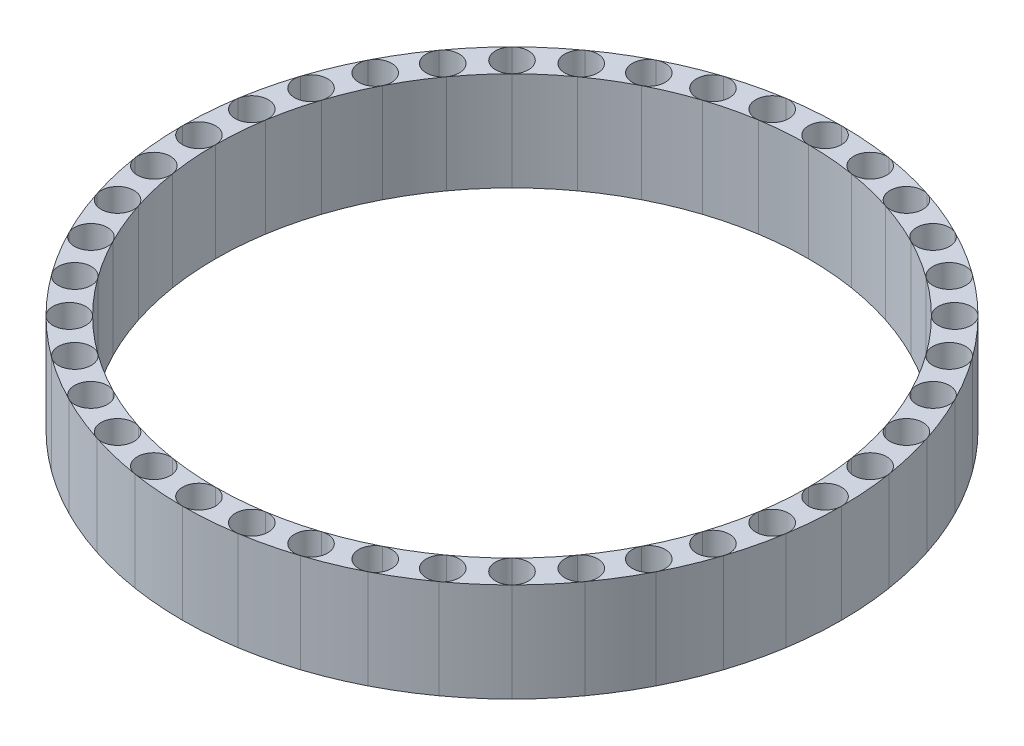
from build123d import *

# Parameters (mm, degrees)
SKETCH1_R           = 127
BOSS_EXTRUDE2_DEPTH = 38.1
SKETCH5_R           = 114.3
CUT_EXTRUDE1_DEPTH  = 39.1
SKETCH6_R           = 6.35
CUT_EXTRUDE2_DEPTH  = 39.1


with BuildPart() as part:
    # Sketch1 → Boss-Extrude2 (new body)
    with BuildSketch(Plane(origin=(0, 0, 0), x_dir=(1, 0, 0), z_dir=(0, 1, 0))):
        Circle(SKETCH1_R)
    extrude(amount=BOSS_EXTRUDE2_DEPTH)

    # Sketch5 → Cut-Extrude1 (cut, through all)
    with BuildSketch(Plane(origin=(0, 38.1, 0), x_dir=(1, 0, 0), z_dir=(0, 1, 0))):
        Circle(SKETCH5_R)
    extrude(amount=-CUT_EXTRUDE1_DEPTH, mode=Mode.SUBTRACT)

    # Sketch6 → Cut-Extrude2 (cut, through all)
    with BuildSketch(Plane(origin=(0, 0, 0), x_dir=(-1, 0, 0), z_dir=(0, -1, 0))):
        with Locations((0, 120.65)):
            Circle(SKETCH6_R)
        with Locations((18.873818207, 119.164598293)):
            Circle(SKETCH6_R)
        with Locations((37.282900371, 114.744968691)):
            Circle(SKETCH6_R)
        with Locations((54.773953794, 107.499937143)):
            Circle(SKETCH6_R)
        with Locations((70.916290689, 97.607900371)):
            Circle(SKETCH6_R)
        with Locations((85.31243315, 85.31243315)):
            Circle(SKETCH6_R)
        with Locations((97.607900371, 70.916290689)):
            Circle(SKETCH6_R)
        with Locations((107.499937143, 54.773953794)):
            Circle(SKETCH6_R)
        with Locations((114.744968691, 37.282900371)):
            Circle(SKETCH6_R)
        with Locations((119.164598293, 18.873818207)):
            Circle(SKETCH6_R)
        with Locations((120.65, 0)):
            Circle(SKETCH6_R)
        with Locations((119.164598293, -18.873818207)):
            Circle(SKETCH6_R)
        with Locations((114.744968691, -37.282900371)):
            Circle(SKETCH6_R)
        with Locations((107.499937143, -54.773953794)):
            Circle(SKETCH6_R)
        with Locations((97.607900371, -70.916290689)):
            Circle(SKETCH6_R)
        with Locations((85.31243315, -85.31243315)):
            Circle(SKETCH6_R)
        with Locations((70.916290689, -97.607900371)):
            Circle(SKETCH6_R)
        with Locations((54.773953794, -107.499937143)):
            Circle(SKETCH6_R)
        with Locations((37.282900371, -114.744968691)):
            Circle(SKETCH6_R)
        with Locations((18.873818207, -119.164598293)):
            Circle(SKETCH6_R)
        with Locations((0, -120.65)):
            Circle(SKETCH6_R)
        with Locations((-18.873818207, -119.164598293)):
            Circle(SKETCH6_R)
        with Locations((-37.282900371, -114.744968691)):
            Circle(SKETCH6_R)
        with Locations((-54.773953794, -107.499937143)):
            Circle(SKETCH6_R)
        with Locations((-70.916290689, -97.607900371)):
            Circle(SKETCH6_R)
        with Locations((-85.31243315, -85.31243315)):
            Circle(SKETCH6_R)
        with Locations((-97.607900371, -70.916290689)):
            Circle(SKETCH6_R)
        with Locations((-107.499937143, -54.773953794)):
            Circle(SKETCH6_R)
        with Locations((-114.744968691, -37.282900371)):
            Circle(SKETCH6_R)
        with Locations((-119.164598293, -18.873818207)):
            Circle(SKETCH6_R)
        with Locations((-120.65, 0)):
            Circle(SKETCH6_R)
        with Locations((-119.164598293, 18.873818207)):
            Circle(SKETCH6_R)
        with Locations((-114.744968691, 37.282900371)):
            Circle(SKETCH6_R)
        with Locations((-107.499937143, 54.773953794)):
            Circle(SKETCH6_R)
        with Locations((-97.607900371, 70.916290689)):
            Circle(SKETCH6_R)
        with Locations((-85.31243315, 85.31243315)):
            Circle(SKETCH6_R)
        with Locations((-70.916290689, 97.607900371)):
            Circle(SKETCH6_R)
        with Locations((-54.773953794, 107.499937143)):
            Circle(SKETCH6_R)
        with Locations((-37.282900371, 114.744968691)):
            Circle(SKETCH6_R)
        with Locations((-18.873818207, 119.164598293)):
            Circle(SKETCH6_R)
    extrude(amount=-CUT_EXTRUDE2_DEPTH, mode=Mode.SUBTRACT)


solid = part.part
